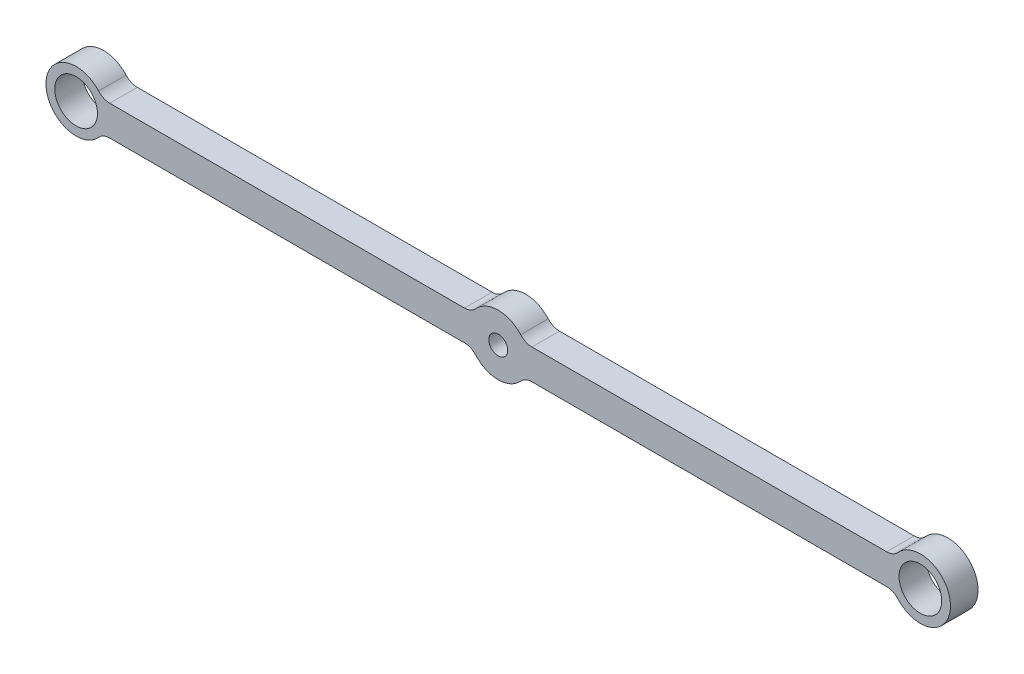
from build123d import *

# Parameters (mm, degrees)
SKETCH1_R           = 4.49961
SKETCH1_R_2         = 1.9939
BOSS_EXTRUDE1_DEPTH = 5.80136
FILLET1_R           = 3.175


with BuildPart() as part:
    # Sketch1 → Boss-Extrude1 (new body)
    with BuildSketch(Plane.XY):
        with BuildLine():
            Line((-83.400738686, -3.175), (-5.499261314, -3.175))
            ThreePointArc((-5.499261314, -3.175), (0, -6.35), (5.499261314, -3.175))
            Line((5.499261314, -3.175), (83.400738686, -3.175))
            ThreePointArc((83.400738686, -3.175), (95.25, 0), (83.400738686, 3.175))
            Line((83.400738686, 3.175), (5.499261314, 3.175))
            ThreePointArc((5.499261314, 3.175), (0, 6.35), (-5.499261314, 3.175))
            Line((-5.499261314, 3.175), (-83.400738686, 3.175))
            ThreePointArc((-83.400738686, 3.175), (-95.25, 0), (-83.400738686, -3.175))
        make_face()
        with Locations((-88.9, 0)):
            Circle(SKETCH1_R, mode=Mode.SUBTRACT)
        Circle(SKETCH1_R_2, mode=Mode.SUBTRACT)
        with Locations((88.9, 0)):
            Circle(SKETCH1_R, mode=Mode.SUBTRACT)
    extrude(amount=BOSS_EXTRUDE1_DEPTH)

    # Fillet1
    fillet1_edges = [part.edges().sort_by_distance(p)[0] for p in [
        (-83.400738686, 3.175, 2.90068),
        (-5.499261314, 3.175, 2.90068),
        (5.499261314, 3.175, 2.90068),
        (83.400738686, 3.175, 2.90068),
        (83.400738686, -3.175, 2.90068),
        (5.499261314, -3.175, 2.90068),
        (-5.499261314, -3.175, 2.90068),
        (-83.400738686, -3.175, 2.90068),
    ]]
    fillet(fillet1_edges, radius=FILLET1_R)


solid = part.part
